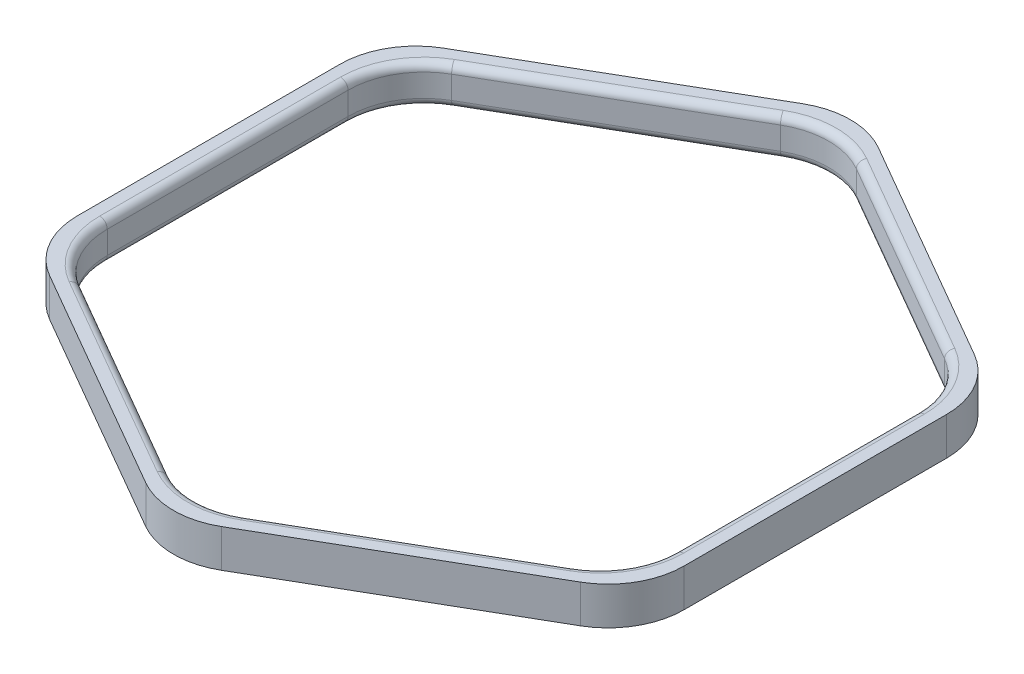
from build123d import *

# Parameters (mm, degrees)
ESTRUSIONE_SOTTILE1_DEPTH = 5
RACCORDO1_R               = 10
RACCORDO2_R               = 1


with BuildPart() as part:
    # Schizzo2 → Estrusione-Sottile1 (new body)
    with BuildSketch(Plane(origin=(0, 0, 0), x_dir=(1, 0, 0), z_dir=(0, 1, 0))):
        Polygon((40, 23.094010768), (0, 46.188021535), (-40, 23.094010768), (-40, -23.094010768), (0, -46.188021535), (40, -23.094010768), align=None)
        Polygon((37.5, 21.650635095), (0, 43.301270189), (-37.5, 21.650635095), (-37.5, -21.650635095), (0, -43.301270189), (37.5, -21.650635095), align=None, mode=Mode.SUBTRACT)
    extrude(amount=ESTRUSIONE_SOTTILE1_DEPTH)

    # Raccordo1
    raccordo1_edges = [part.edges().sort_by_distance(p)[0] for p in [
        (37.5, 2.5, 21.650635095),
        (37.5, 2.5, -21.650635095),
        (0, 2.5, -43.301270189),
        (-37.5, 2.5, -21.650635095),
        (-37.5, 2.5, 21.650635095),
        (0, 2.5, 43.301270189),
        (40, 2.5, 23.094010768),
        (0, 2.5, 46.188021535),
        (-40, 2.5, 23.094010768),
        (-40, 2.5, -23.094010768),
        (0, 2.5, -46.188021535),
        (40, 2.5, -23.094010768),
    ]]
    fillet(raccordo1_edges, radius=RACCORDO1_R)

    # Raccordo2
    raccordo2_edges = [part.edges().sort_by_distance(p)[0] for p in [
        (37.5, 0, 0),
        (18.75, 0, -32.475952642),
        (-18.75, 0, -32.475952642),
        (-37.5, 0, 0),
        (-18.75, 0, 32.475952642),
        (18.75, 0, 32.475952642),
        (18.75, 5, -32.475952642),
        (37.5, 5, 0),
        (18.75, 5, 32.475952642),
        (-18.75, 5, 32.475952642),
        (-37.5, 5, 0),
        (-18.75, 5, -32.475952642),
        (36.160254038, 0, 20.877132403),
        (36.160254038, 5, 20.877132403),
        (0, 0, 41.754264805),
        (0, 5, 41.754264805),
        (36.160254038, 0, -20.877132403),
        (36.160254038, 5, -20.877132403),
        (0, 0, -41.754264805),
        (0, 5, -41.754264805),
        (-36.160254038, 0, -20.877132403),
        (-36.160254038, 5, -20.877132403),
        (-36.160254038, 0, 20.877132403),
        (-36.160254038, 5, 20.877132403),
    ]]
    fillet(raccordo2_edges, radius=RACCORDO2_R)


solid = part.part
